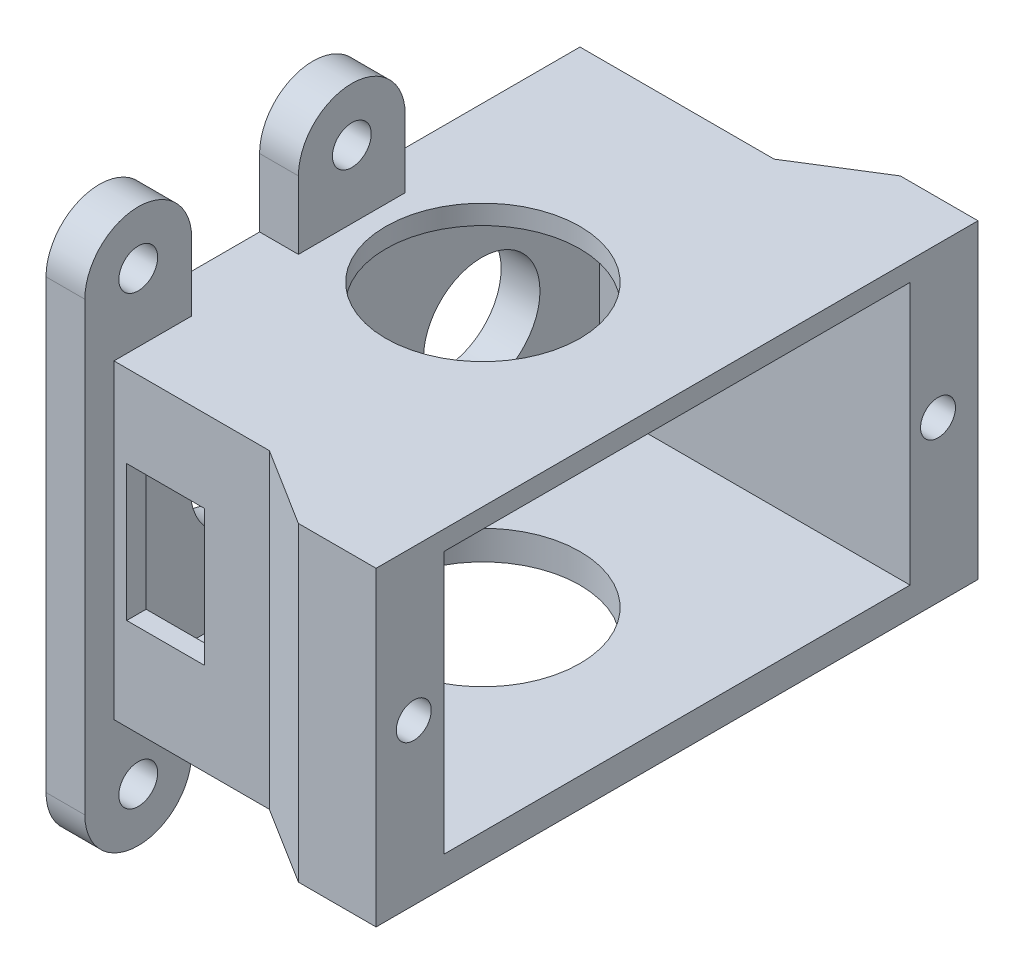
from build123d import *

# Parameters (mm, degrees)
P_IDAT_VYSUNUT_M1_DEPTH   = 15
P_IDAT_VYSUNUT_M2_DEPTH   = 15
SKICA10_W                 = 16
SKICA10_H                 = 24
ODEBRAT_VYSUNUT_M7_DEPTH  = 13.5
SKICA11_W                 = 2.5
SKICA11_H                 = 15
P_IDAT_VYSUNUT_M3_DEPTH   = 4
SKICA12_R                 = 0.9
ODEBRAT_VYSUNUT_M8_DEPTH  = 4
SKICA13_W                 = 4
SKICA13_H                 = 7
ODEBRAT_VYSUNUT_M9_DEPTH  = 4
SKICA17_W                 = 38.25
SKICA17_H                 = 32.5
ODEBRAT_VYSUNUT_M10_DEPTH = 16
P_IDAT_VYSUNUT_M4_DEPTH   = 1
SKICA20_R                 = 1
P_IDAT_VYSUNUT_M5_DEPTH   = 2
SKICA21_R                 = 5
ODEBRAT_VYSUNUT_M11_DEPTH = 22
LINPOLE1_COUNT            = 2
LINPOLE1_PITCH            = 11
SKICA22_R                 = 3
ODEBRAT_VYSUNUT_M12_DEPTH = 5
P_IDAT_VYSUNUT_M6_DEPTH   = 16
SKICA24_W                 = 2
SKICA24_H                 = 1.5
P_IDAT_VYSUNUT_M7_DEPTH   = 16


with BuildPart() as part:
    # Skica1 → Přidat vysunutím1 (new body)
    with BuildSketch(Plane(origin=(0, 0, 0), x_dir=(1, 0, 0), z_dir=(0, 1, 0))):
        Polygon((0, -11), (0, 11), (-3.25, 14.25), (-30.25, 14.25), (-30.25, 16.25), (-2.421572875, 16.25), (2, 11.828427125), (2, -11.828427125), (-2.421572875, -16.25), (-30.25, -16.25), (-30.25, -14.25), (-3.25, -14.25), align=None)
    extrude(amount=P_IDAT_VYSUNUT_M1_DEPTH)

    # Skica8 → Přidat vysunutím2 (add)
    with BuildSketch(Plane.XZ):
        Polygon((-0.343145751, 14.171572875), (26, 14.171572875), (26, -11.828427125), (2, -11.828427125), (2, 11.828427125), align=None)
    extrude(amount=-P_IDAT_VYSUNUT_M2_DEPTH)

    # Skica10 → Odebrat vysunutím7 (cut)
    with BuildSketch(Plane(origin=(0, 15, 0), x_dir=(1, 0, 0), z_dir=(0, 1, 0))):
        with Locations((18, -1.171572875)):
            Rectangle(SKICA10_W, SKICA10_H)
    extrude(amount=-ODEBRAT_VYSUNUT_M7_DEPTH, mode=Mode.SUBTRACT)

    # Skica11 → Přidat vysunutím3 (add)
    with BuildSketch(Plane(origin=(26, 0, 0), x_dir=(0, 0, -1), z_dir=(1, 0, 0))):
        with Locations((-15.421572875, 7.5)):
            Rectangle(SKICA11_W, SKICA11_H)
        with Locations((13.078427125, 7.5)):
            Rectangle(SKICA11_W, SKICA11_H)
    extrude(amount=-P_IDAT_VYSUNUT_M3_DEPTH)

    # Skica12 → Odebrat vysunutím8 (cut)
    with BuildSketch(Plane(origin=(26, 0, 0), x_dir=(0, 0, -1), z_dir=(1, 0, 0))):
        with Locations((-14.730217843, 8.25)):
            Circle(SKICA12_R)
        with Locations((12.269782157, 8.25)):
            Circle(SKICA12_R)
    extrude(amount=-ODEBRAT_VYSUNUT_M8_DEPTH, mode=Mode.SUBTRACT)

    # Skica13 → Odebrat vysunutím9 (cut)
    with BuildSketch(Plane.XY.offset(14.171572875)):
        with Locations((12.656854249, 8.25)):
            Rectangle(SKICA13_W, SKICA13_H)
    extrude(amount=-ODEBRAT_VYSUNUT_M9_DEPTH, mode=Mode.SUBTRACT)

    # Skica17 → Odebrat vysunutím10 (cut, through all)
    with BuildSketch(Plane(origin=(0, 15, 0), x_dir=(1, 0, 0), z_dir=(0, 1, 0))):
        with Locations((-11.125, 0)):
            Rectangle(SKICA17_W, SKICA17_H)
    extrude(amount=-ODEBRAT_VYSUNUT_M10_DEPTH, mode=Mode.SUBTRACT)

    # Skica19 → Přidat vysunutím4 (add)
    with BuildSketch(Plane(origin=(0, 15, 0), x_dir=(1, 0, 0), z_dir=(0, 1, 0))):
        Polygon((8, 11.828427125), (22, 11.828427125), (22, 14.328427125), (26, 14.328427125), (26, -16.671572875), (22, -16.671572875), (22, -14.171572875), (8, -14.171572875), align=None)
    extrude(amount=P_IDAT_VYSUNUT_M4_DEPTH)

    # Skica20 → Přidat vysunutím5 (add)
    with BuildSketch(Plane.ZY.offset(-8)):
        with BuildLine():
            Line((10.171572875, -3.5), (10.171572875, 0))
            Line((10.171572875, 0), (15.671572875, 0))
            Line((15.671572875, 0), (15.671572875, -3.5))
            ThreePointArc((15.671572875, -3.5), (12.921572875, -6.25), (10.171572875, -3.5))
        make_face()
        with Locations((12.921572875, -3.5)):
            Circle(SKICA20_R, mode=Mode.SUBTRACT)
        with BuildLine():
            Line((10.171572875, 16), (15.671572875, 16))
            Line((15.671572875, 16), (15.671572875, 19.5))
            ThreePointArc((15.671572875, 19.5), (12.921572875, 22.25), (10.171572875, 19.5))
            Line((10.171572875, 19.5), (10.171572875, 16))
        make_face()
        with Locations((12.921572875, 19.5)):
            Circle(SKICA20_R, mode=Mode.SUBTRACT)
    p_idat_vysunut_m5 = extrude(amount=-P_IDAT_VYSUNUT_M5_DEPTH)

    # Skica21 → Odebrat vysunutím11 (cut)
    with BuildSketch(Plane(origin=(0, 16, 0), x_dir=(1, 0, 0), z_dir=(0, 1, 0))):
        with Locations((16, -1.171572875)):
            Circle(SKICA21_R)
    extrude(amount=-ODEBRAT_VYSUNUT_M11_DEPTH, mode=Mode.SUBTRACT)

    # LinPole1: Přidat vysunutím5 ×2
    with Locations(*[(0, 0, -i * LINPOLE1_PITCH) for i in range(1, LINPOLE1_COUNT)]):
        add(p_idat_vysunut_m5)

    # Skica22 → Odebrat vysunutím12 (cut)
    with BuildSketch(Plane(origin=(10, 0, 0), x_dir=(0, 0, -1), z_dir=(1, 0, 0))):
        with Locations((-7.230444291, 8.25)):
            Circle(SKICA22_R)
        with Locations((4.769102832, 8.145746213)):
            Circle(SKICA22_R)
    extrude(amount=-ODEBRAT_VYSUNUT_M12_DEPTH, mode=Mode.SUBTRACT)

    # Skica23 → Přidat vysunutím6 (add)
    with BuildSketch(Plane(origin=(0, 16, 0), x_dir=(1, 0, 0), z_dir=(0, 1, 0))):
        Polygon((22, 14.328427125), (18, 11.828427125), (22, 11.828427125), align=None)
        Polygon((22, -14.171572875), (18, -14.171572875), (22, -16.671572875), align=None)
    extrude(amount=-P_IDAT_VYSUNUT_M6_DEPTH)

    # Skica24 → Přidat vysunutím7 (add)
    with BuildSketch(Plane.XZ.offset(-16)):
        with Locations((9, 14.921572875)):
            Rectangle(SKICA24_W, SKICA24_H)
    extrude(amount=P_IDAT_VYSUNUT_M7_DEPTH)


solid = part.part
